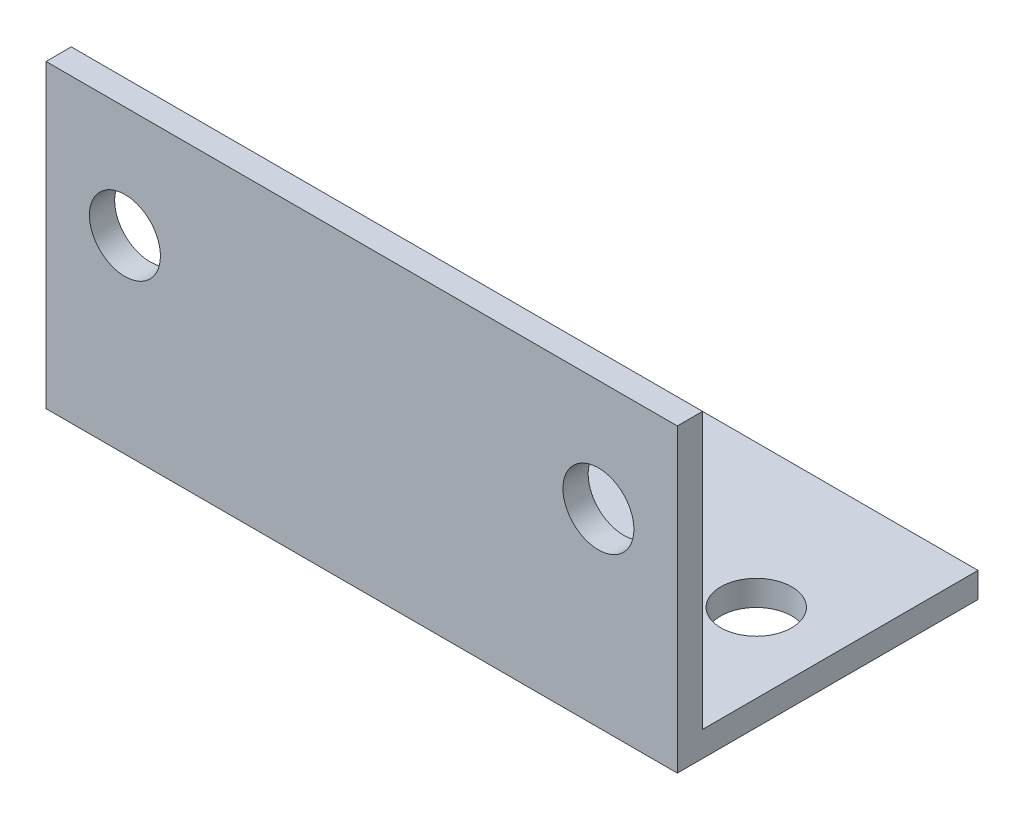
from build123d import *

# Parameters (mm, degrees)
BOSS_EXTRUDE1_DEPTH  = 20
M4_CLEARANCE_HOLE1_D = 4.5
M4_CLEARANCE_HOLE2_D = 4.5


with BuildPart() as part:
    # Sketch1 → Boss-Extrude1 (new body, symmetric)
    with BuildSketch(Plane(origin=(0, 0, 0), x_dir=(0, 0, -1), z_dir=(1, 0, 0))):
        Polygon((0, 0), (0, 19.05), (1.6, 19.05), (1.6, 1.6), (19.05, 1.6), (19.05, 0), align=None)
    extrude(amount=BOSS_EXTRUDE1_DEPTH, both=True)

    # M4 Clearance Hole1 (through all)
    with Locations(Plane.XY):
        with Locations((-15, 12), (15, 12)):
            Hole(M4_CLEARANCE_HOLE1_D / 2)

    # M4 Clearance Hole2 (through all)
    with Locations(Plane(origin=(0, 0, 0), x_dir=(-1, 0, 0), z_dir=(0, -1, 0))):
        with Locations((-15, 10), (15, 10)):
            Hole(M4_CLEARANCE_HOLE2_D / 2)


solid = part.part
